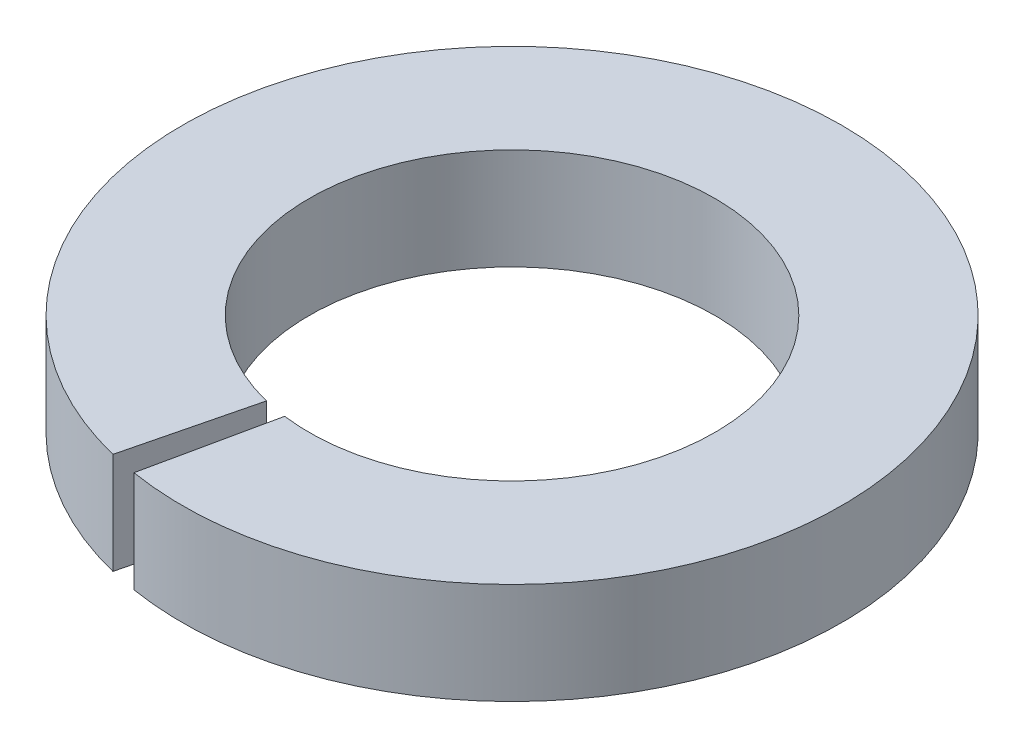
from build123d import *

# Parameters (mm, degrees)
EXTRUDE_1_DEPTH = 1


with BuildPart() as part:
    # Эскиз1 → Бобышка-Вытянуть1 (new body)
    with BuildSketch(Plane(origin=(0, 0, 0), x_dir=(1, 0, 0), z_dir=(0, 1, 0))):
        with BuildLine():
            Line((-0.480978539, -1.941303594), (-0.781590125, -3.154618341))
            ThreePointArc((-0.781590125, -3.154618341), (0.651870907, 3.183954196), (-0.521060083, -3.20795829))
            Line((-0.521060083, -3.20795829), (-0.259794841, -1.983054876))
            ThreePointArc((-0.259794841, -1.983054876), (0.370974517, 1.965293339), (-0.480978539, -1.941303594))
        make_face()
    extrude(amount=EXTRUDE_1_DEPTH)


solid = part.part
